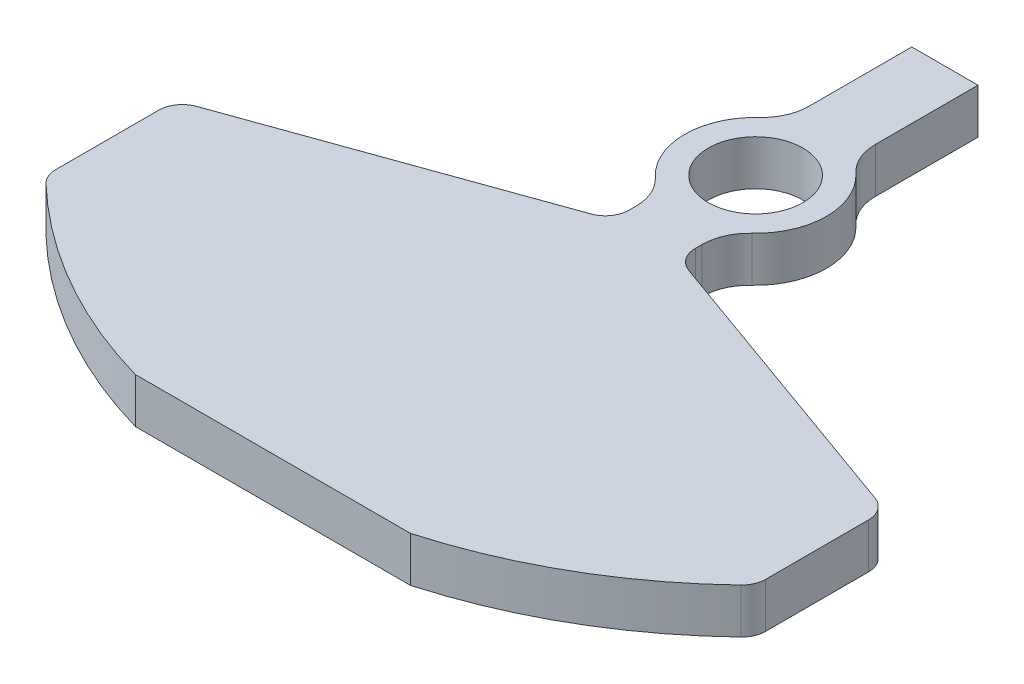
from build123d import *

# Parameters (mm, degrees)
SKETCH1_R                  = 10
BOSS_EXTRUDE1_DEPTH        = 9.525
FILLET1_R                  = 10
FILLET2_R                  = 5
M8X1_25_TAPPED_HOLE1_D     = 6.8
M8X1_25_TAPPED_HOLE1_DEPTH = 22.25
M8X1_25_TAPPED_HOLE1_TIP   = 2.042926105


with BuildPart() as part:
    # Sketch1 → Boss-Extrude1 (new body)
    with BuildSketch(Plane(origin=(0, 0, 0), x_dir=(1, 0, 0), z_dir=(0, 1, 0))):
        with BuildLine():
            Line((-7, 40), (7, 40))
            Line((7, 40), (7, 13.266499161))
            ThreePointArc((7, 13.266499161), (15, 0), (7, -13.266499161))
            Line((7, -13.266499161), (7, -23.266499161))
            Line((7, -23.266499161), (75, -47.63233641))
            Line((75, -47.63233641), (75, -75))
            ThreePointArc((75, -75), (53.765490493, -91.429054638), (29.086079144, -102))
            Line((29.086079144, -102), (-29.086079144, -102))
            ThreePointArc((-29.086079144, -102), (-53.765490493, -91.429054638), (-75, -75))
            Line((-75, -75), (-75, -47.63233641))
            Line((-75, -47.63233641), (-7, -23.266499161))
            Line((-7, -23.266499161), (-7, -13.266499161))
            ThreePointArc((-7, -13.266499161), (-15, 0), (-7, 13.266499161))
            Line((-7, 13.266499161), (-7, 40))
        make_face()
        Circle(SKETCH1_R, mode=Mode.SUBTRACT)
    extrude(amount=BOSS_EXTRUDE1_DEPTH)

    # Fillet1
    fillet1_edges = [part.edges().sort_by_distance(p)[0] for p in [
        (7, 4.7625, -13.266499161),
        (7, 4.7625, 13.266499161),
        (-7, 4.7625, 13.266499161),
        (-7, 4.7625, -13.266499161),
    ]]
    fillet(fillet1_edges, radius=FILLET1_R)

    # Fillet2
    fillet2_edges = [part.edges().sort_by_distance(p)[0] for p in [
        (7, 4.7625, 23.266499161),
        (75, 4.7625, 47.63233641),
        (75, 4.7625, 75),
        (-75, 4.7625, 75),
        (-75, 4.7625, 47.63233641),
        (-7, 4.7625, 23.266499161),
    ]]
    fillet(fillet2_edges, radius=FILLET2_R)

    # M8x1.25 Tapped Hole1
    with Locations(Plane(origin=(0, 0, -40), x_dir=(-1, 0, 0), z_dir=(0, 0, -1))):
        with Locations((0, 4.7625)):
            Hole(M8X1_25_TAPPED_HOLE1_D / 2, depth=M8X1_25_TAPPED_HOLE1_DEPTH)
            with Locations((0, 0, -(M8X1_25_TAPPED_HOLE1_DEPTH + M8X1_25_TAPPED_HOLE1_TIP / 2))):  # 118° drill point
                Cone(0, M8X1_25_TAPPED_HOLE1_D / 2, M8X1_25_TAPPED_HOLE1_TIP, mode=Mode.SUBTRACT)


solid = part.part
